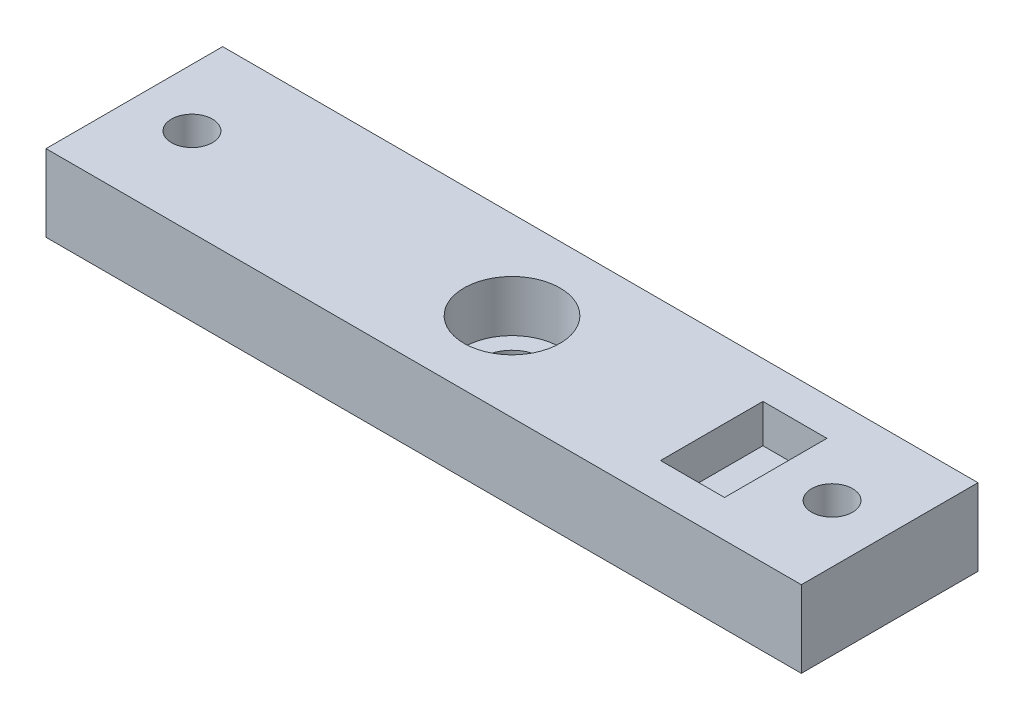
from build123d import *

# Parameters (mm, degrees)
ESQUISSE1_W             = 29.5
ESQUISSE1_H             = 13.8
ESQUISSE1_R             = 1.6
BOSS_EXTRU_1_DEPTH      = 6
ESQUISSE2_R             = 2.35
ENL_V_MAT_EXTRU_1_DEPTH = 7
ESQUISSE3_R             = 3.75
ENL_V_MAT_EXTRU_2_DEPTH = 4
ESQUISSE5_W             = 5
ESQUISSE5_H             = 8
ENL_V_MAT_EXTRU_3_DEPTH = 3


with BuildPart() as part:
    # Esquisse1 → Boss.-Extru.1 (new body)
    with BuildSketch(Plane(origin=(0, 0, 0), x_dir=(1, 0, 0), z_dir=(0, 1, 0))):
        with Locations((14.75, 6.9)):
            Rectangle(ESQUISSE1_W, ESQUISSE1_H)
        with Locations((25, 6.9)):
            Circle(ESQUISSE1_R, mode=Mode.SUBTRACT)
    extrude(amount=BOSS_EXTRU_1_DEPTH)

    # Esquisse2 → Enlèv. mat.-Extru.1 (cut, through all)
    with BuildSketch(Plane(origin=(0, 6, 0), x_dir=(1, 0, 0), z_dir=(0, 1, 0))):
        with Locations((0, 6.9)):
            Circle(ESQUISSE2_R)
    extrude(amount=-ENL_V_MAT_EXTRU_1_DEPTH, mode=Mode.SUBTRACT)

    # Esquisse3 → Enlèv. mat.-Extru.2 (cut)
    with BuildSketch(Plane(origin=(0, 6, 0), x_dir=(1, 0, 0), z_dir=(0, 1, 0))):
        with Locations((0, 6.9)):
            Circle(ESQUISSE3_R)
    extrude(amount=-ENL_V_MAT_EXTRU_2_DEPTH, mode=Mode.SUBTRACT)

    # Symétrie1: part across plane


with BuildPart() as part_1:
    add(part.part)
    add(part.part.mirror(Plane(origin=(0, 6, 0), x_dir=(0, 0, 1), z_dir=(1, 0, 0))))

    # Esquisse5 → Enlèv. mat.-Extru.3 (cut)
    with BuildSketch(Plane.XZ.offset(-6)):
        with Locations((18.1, -6.9)):
            Rectangle(ESQUISSE5_W, ESQUISSE5_H)
    extrude(amount=ENL_V_MAT_EXTRU_3_DEPTH, mode=Mode.SUBTRACT)


solid = part_1.part
